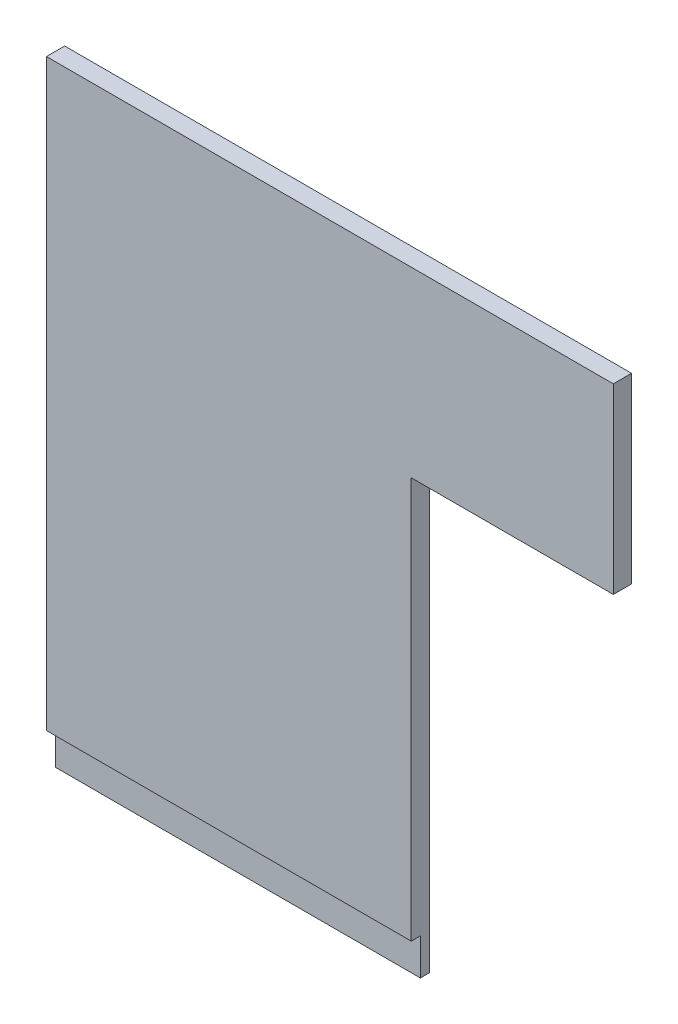
from build123d import *

# Parameters (mm, degrees)
BOSS_EXTRUDE1_DEPTH = 3.175
SKETCH2_W           = 63.5
SKETCH2_H           = 6.35
CUT_EXTRUDE1_DEPTH  = 1.5875


with BuildPart() as part:
    # Sketch1 → Boss-Extrude1 (new body)
    with BuildSketch(Plane.XY):
        Polygon((0, 0), (63.5, 0), (63.5, 76.2), (98.679, 76.2), (98.679, 107.95), (63.5, 107.95), (0, 107.95), align=None)
    extrude(amount=BOSS_EXTRUDE1_DEPTH)

    # Sketch2 → Cut-Extrude1 (cut)
    with BuildSketch(Plane.XY.offset(3.175)):
        with Locations((31.75, 3.175)):
            Rectangle(SKETCH2_W, SKETCH2_H)
    extrude(amount=-CUT_EXTRUDE1_DEPTH, mode=Mode.SUBTRACT)


solid = part.part
